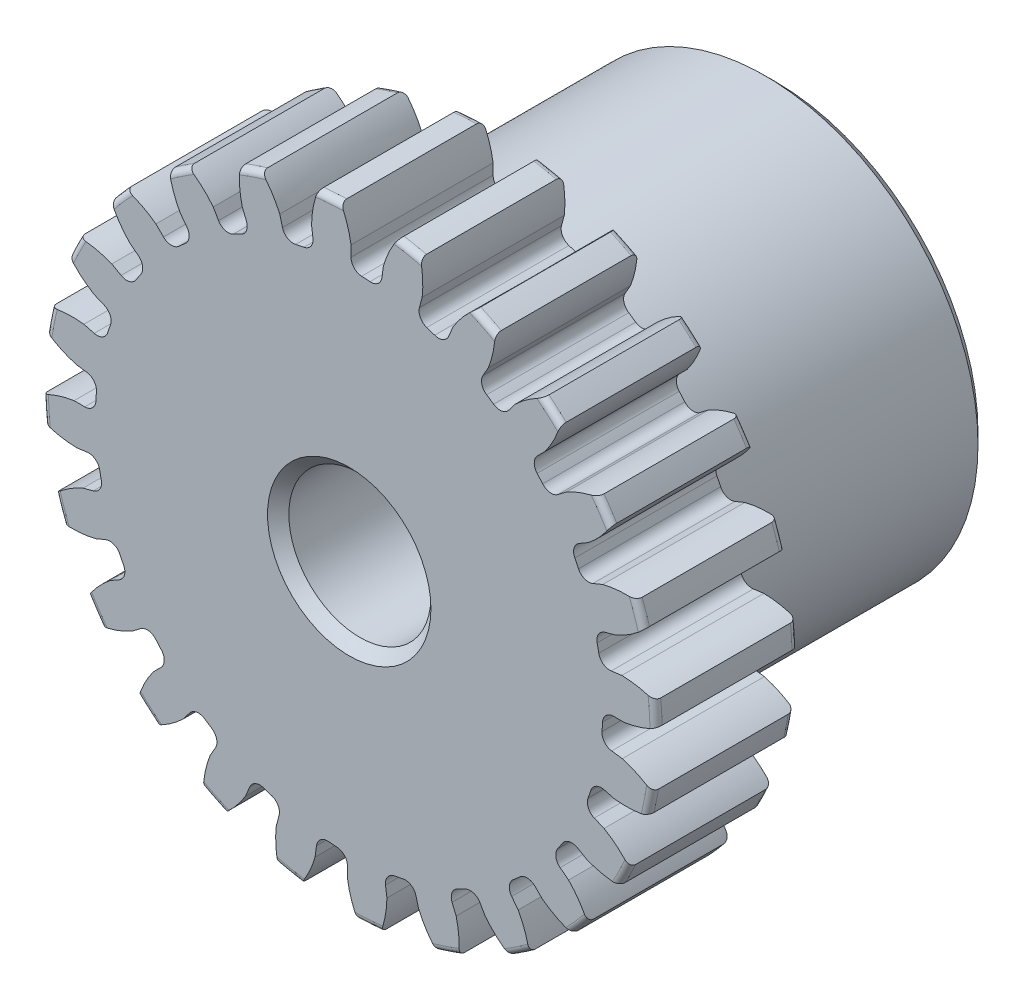
from build123d import *

# Parameters (mm, degrees)
SKETCH1_R                = 6.858
BOSS_EXTRUDE1_DEPTH      = 3.175
SKETCH2_W                = 6.35
SKETCH2_H                = 4.7625
FILLET2_R                = 0.13716
CUT_EXTRUDE1_DEPTH       = 10.525
FILLET1_R                = 0.2493645
CIRPATTERN1_COUNT        = 24
FILLET1_OF_CIRPATTERN1_R = 0.2493645
SKETCH5_R                = 1.5875
CUT_EXTRUDE2_DEPTH       = 10.525
CHAMFER1_SIZE            = 0.238125


with BuildPart() as part:
    # Sketch1 → Boss-Extrude1 (new body)
    with BuildSketch(Plane.XY):
        Circle(SKETCH1_R)
    extrude(amount=-BOSS_EXTRUDE1_DEPTH)

    # Sketch2 → Revolve1 (revolve)
    with BuildSketch(Plane(origin=(0, 0, 0), x_dir=(0, 0, -1), z_dir=(1, 0, 0))):
        with Locations((6.35, 2.38125)):
            Rectangle(SKETCH2_W, SKETCH2_H)
    revolve(axis=Axis((0, 0, -3.175), (0, 0, -1)))

    # Fillet2
    fillet2_edges = [part.edges().sort_by_distance(p)[0] for p in [
        (-6.858, 0, 0),
        (-6.858, 0, -3.175),
        (0, -4.7625, -3.175),
    ]]
    fillet(fillet2_edges, radius=FILLET2_R)

    # Sketch4 → Cut-Extrude1 (cut, through all)
    with BuildSketch(Plane.XY):
        with BuildLine():
            Line((0.039756598, 6.147608965), (0.039756598, 5.667235552))
            ThreePointArc((0.039756598, 5.667235552), (0.370664925, 5.655240658), (0.700307924, 5.623940629))
            Line((0.700307924, 5.623940629), (0.763009382, 6.100204362))
            add(Edge.make_bspline(
                [(1.610091796, 7.308398352), (0.967896203, 6.814744352), (0.763009382, 6.100204362)],
                knots=[0, 0, 0, 1, 1, 1], degree=2))
            ThreePointArc((1.610091796, 7.308398352), (0.489455554, 7.467631172), (-0.642377547, 7.456033339))
            add(Edge.make_bspline(
                [(-0.642377547, 7.456033339), (-0.070110979, 6.882779097), (0.039756598, 6.147608965)],
                knots=[0, 0, 0, 1, 1, 1], degree=2))
        make_face()
    cut_extrude1 = extrude(amount=-CUT_EXTRUDE1_DEPTH, mode=Mode.SUBTRACT)

    # Fillet1
    fillet1_edges = [part.edges().sort_by_distance(p)[0] for p in [
        (0.700307924, 5.623940629, -1.5875),
        (0.039756598, 5.667235552, -1.5875),
    ]]
    fillet(fillet1_edges, radius=FILLET1_R)

    # CirPattern1: Cut-Extrude1 ×24 about axis
    cirpattern1_axis = Axis((0, 0, -3.175), (0, 0, 1))
    for i in range(1, CIRPATTERN1_COUNT):
        add(cut_extrude1.rotate(cirpattern1_axis, i * 360 / CIRPATTERN1_COUNT), mode=Mode.SUBTRACT)

    # Fillet1 of CirPattern1
    fillet1_of_cirpattern1_edges = [part.edges().sort_by_distance(p)[0] for p in [
        (-0.779137434, 5.613562527, -1.5875),
        (-1.428386569, 5.484418948, -1.5875),
        (-2.205485862, 5.220629416, -1.5875),
        (-2.799187552, 4.927848256, -1.5875),
        (-3.481534074, 4.471919038, -1.5875),
        (-3.979228529, 4.03545285, -1.5875),
        (-4.520321493, 3.418454767, -1.5875),
        (-4.888091658, 2.868048, -1.5875),
        (-5.251056471, 2.132028453, -1.5875),
        (-5.463839419, 1.505190419, -1.5875),
        (-5.623940629, 0.700307924, -1.5875),
        (-5.667235552, 0.039756598, -1.5875),
        (-5.613562527, -0.779137434, -1.5875),
        (-5.484418948, -1.428386569, -1.5875),
        (-5.220629416, -2.205485862, -1.5875),
        (-4.927848256, -2.799187552, -1.5875),
        (-4.471919038, -3.481534074, -1.5875),
        (-4.03545285, -3.979228529, -1.5875),
        (-3.418454767, -4.520321493, -1.5875),
        (-2.868048, -4.888091658, -1.5875),
        (-2.132028453, -5.251056471, -1.5875),
        (-1.505190419, -5.463839419, -1.5875),
        (-0.700307924, -5.623940629, -1.5875),
        (-0.039756598, -5.667235552, -1.5875),
        (0.779137434, -5.613562527, -1.5875),
        (1.428386569, -5.484418948, -1.5875),
        (2.205485862, -5.220629416, -1.5875),
        (2.799187552, -4.927848256, -1.5875),
        (3.481534074, -4.471919038, -1.5875),
        (3.979228529, -4.03545285, -1.5875),
        (4.520321493, -3.418454767, -1.5875),
        (4.888091658, -2.868048, -1.5875),
        (5.251056471, -2.132028453, -1.5875),
        (5.463839419, -1.505190419, -1.5875),
        (5.623940629, -0.700307924, -1.5875),
        (5.667235552, -0.039756598, -1.5875),
        (5.613562527, 0.779137434, -1.5875),
        (5.484418948, 1.428386569, -1.5875),
        (5.220629416, 2.205485862, -1.5875),
        (4.927848256, 2.799187552, -1.5875),
        (4.471919038, 3.481534074, -1.5875),
        (4.03545285, 3.979228529, -1.5875),
        (3.418454767, 4.520321493, -1.5875),
        (2.868048, 4.888091658, -1.5875),
        (2.132028453, 5.251056471, -1.5875),
        (1.505190419, 5.463839419, -1.5875),
    ]]
    fillet(fillet1_of_cirpattern1_edges, radius=FILLET1_OF_CIRPATTERN1_R)

    # Sketch5 → Cut-Extrude2 (cut, through all)
    with BuildSketch(Plane.XY):
        Circle(SKETCH5_R)
    extrude(amount=-CUT_EXTRUDE2_DEPTH, mode=Mode.SUBTRACT)

    # Chamfer1
    chamfer1_edges = [part.edges().sort_by_distance(p)[0] for p in [
        (-1.5875, 0, -9.525),
        (-1.5875, 0, 0),
        (0, -4.7625, -9.525),
    ]]
    chamfer(chamfer1_edges, length=CHAMFER1_SIZE)


solid = part.part
